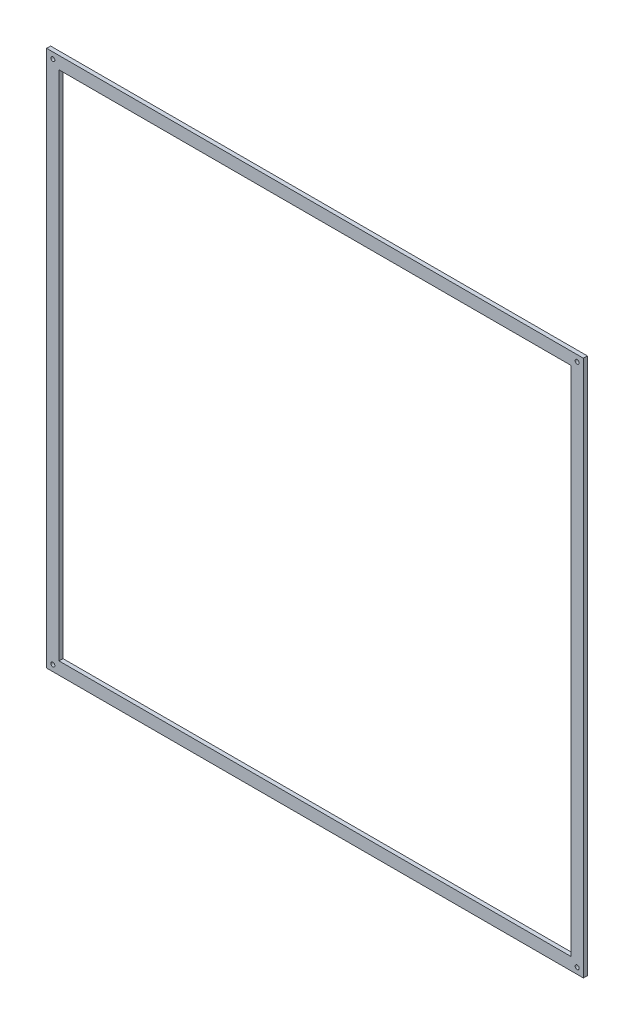
from build123d import *

# Parameters (mm, degrees)
SKETCH1_W           = 1343.502884254
SKETCH1_H           = 1343.502884254
SKETCH1_R           = 5
SKETCH1_W_2         = 1281.27748751
SKETCH1_H_2         = 1281.27748751
BOSS_EXTRUDE1_DEPTH = 10


with BuildPart() as part:
    # Sketch1 → Boss-Extrude1 (new body)
    with BuildSketch(Plane.XY):
        Rectangle(SKETCH1_W, SKETCH1_H)
        with Locations((-656.195092941, 656.195092941)):
            Circle(SKETCH1_R, mode=Mode.SUBTRACT)
        with Locations((656.195092941, 656.195092941)):
            Circle(SKETCH1_R, mode=Mode.SUBTRACT)
        with Locations((656.195092941, -656.195092941)):
            Circle(SKETCH1_R, mode=Mode.SUBTRACT)
        with Locations((-656.195092941, -656.195092941)):
            Circle(SKETCH1_R, mode=Mode.SUBTRACT)
        Rectangle(SKETCH1_W_2, SKETCH1_H_2, mode=Mode.SUBTRACT)
    extrude(amount=BOSS_EXTRUDE1_DEPTH)


solid = part.part
